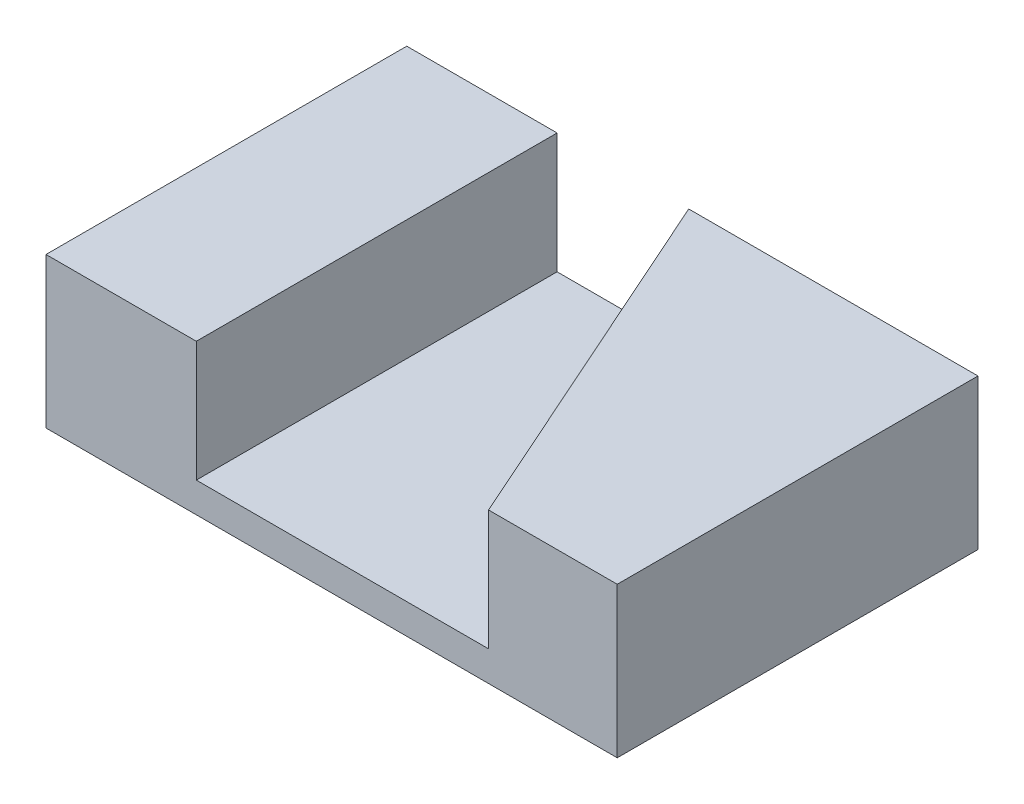
from build123d import *

# Parameters (mm, degrees)
SKETCH_3_W            = 19
SKETCH_3_H            = 12
EXTRUDE_1_DEPTH       = 5
HOLE_WIZARD_M23_D     = 2.1
HOLE_WIZARD_M23_DEPTH = 8
HOLE_WIZARD_M23_TIP   = 0.63090365
CUT_EXTRUDE_1_DEPTH   = 4


with BuildPart() as part:
    # Эскиз3 → Бобышка-Вытянуть1 (new body)
    with BuildSketch(Plane(origin=(0, 0, 0), x_dir=(1, 0, 0), z_dir=(0, 1, 0))):
        with Locations((9.5, 6)):
            Rectangle(SKETCH_3_W, SKETCH_3_H)
    extrude(amount=EXTRUDE_1_DEPTH)

    # Эскиз8 → Отверстие обработанное метчиком M2x0.42 (revolve, cut)
    with BuildSketch(Plane(origin=(12, 3, -12), x_dir=(0, 1, 0), z_dir=(1, 0, 0))):
        Polygon((0, 0), (0, 12), (1.025, 12), (0.8, 11.842453304), (0.8, 0.157546696), (1.025, 0), align=None)
    revolve(axis=Axis((12, 3, -18.35), (0, 0, 1)), mode=Mode.SUBTRACT)

    # Отверстие с зазором M23
    with Locations(Plane.XY):
        with Locations((12, 3)):
            Hole(HOLE_WIZARD_M23_D / 2, depth=HOLE_WIZARD_M23_DEPTH)
            with Locations((0, 0, -(HOLE_WIZARD_M23_DEPTH + HOLE_WIZARD_M23_TIP / 2))):  # 118° drill point
                Cone(0, HOLE_WIZARD_M23_D / 2, HOLE_WIZARD_M23_TIP, mode=Mode.SUBTRACT)

    # Эскиз4 → Вырез-Вытянуть1 (cut)
    with BuildSketch(Plane(origin=(0, 5, 0), x_dir=(1, 0, 0), z_dir=(0, 1, 0))):
        Polygon((5, 12), (5, 0), (14.721289338, 0), (9.378545114, 12), align=None)
    extrude(amount=-CUT_EXTRUDE_1_DEPTH, mode=Mode.SUBTRACT)


solid = part.part
